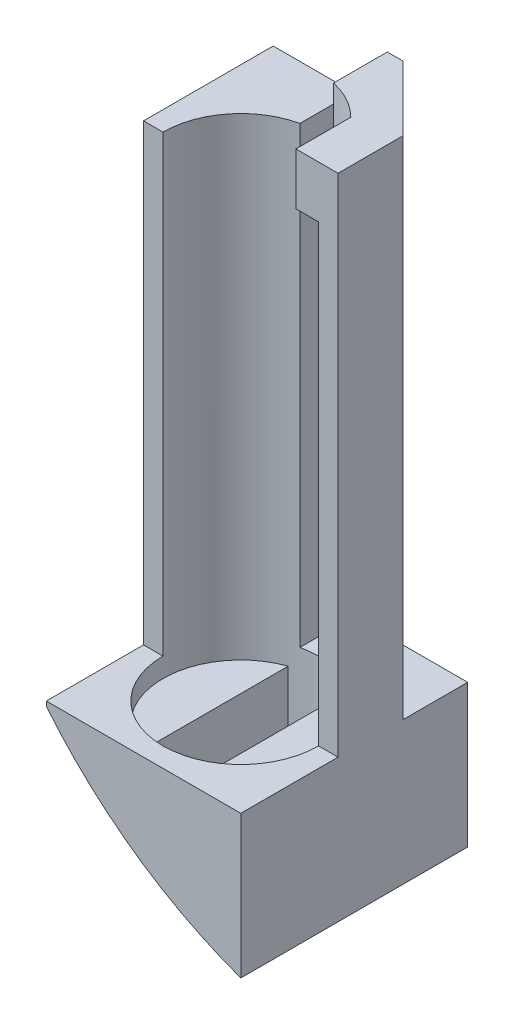
from build123d import *

# Parameters (mm, degrees)
BOSS_EXTRUDE1_DEPTH     = 70
SKETCH5_W               = 30
SKETCH5_H               = 35
BOSS_EXTRUDE3_DEPTH     = 22
SKETCH6_R               = 108.03554
SKETCH6_R_2             = 69
CUT_EXTRUDE1_DEPTH      = 16
CUT_EXTRUDE1_DEPTH_BACK = 21
SKETCH7_R               = 12
CUT_EXTRUDE2_DEPTH      = 3
CUT_EXTRUDE3_DEPTH      = 23
BOSS_EXTRUDE4_DEPTH     = 8


with BuildPart() as part:
    # Sketch1 → Boss-Extrude1 (new body)
    with BuildSketch(Plane(origin=(0, 0, 0), x_dir=(-1, 0, 0), z_dir=(0, 1, 0))):
        with BuildLine():
            Line((-12, 0), (-15, 0))
            Line((-15, 0), (-15, -10))
            Line((-15, -10), (-5, -20))
            Line((-5, -20), (15, -20))
            Line((15, -20), (15, 0))
            Line((15, 0), (12, 0))
            ThreePointArc((12, 0), (9.359487, -7.509993), (2.6, -11.714948))
            Line((2.6, -11.714948), (2.6, -17.2))
            Line((2.6, -17.2), (-2.6, -17.2))
            Line((-2.6, -17.2), (-2.6, -11.714948))
            ThreePointArc((-2.6, -11.714948), (-9.359487, -7.509993), (-12, 0))
        make_face()
    extrude(amount=BOSS_EXTRUDE1_DEPTH)

    # Sketch5 → Boss-Extrude3 (add)
    with BuildSketch(Plane(origin=(0, 0, 0), x_dir=(-1, 0, 0), z_dir=(0, 1, 0))):
        with Locations((0, -2.5)):
            Rectangle(SKETCH5_W, SKETCH5_H)
    extrude(amount=-BOSS_EXTRUDE3_DEPTH)

    # Sketch6 → Cut-Extrude1 (cut, two sides)
    with BuildSketch(Plane(origin=(0, 0, 0), x_dir=(0, 1, 0), z_dir=(0, 0, 1))) as cut_extrude1_sk:
        with Locations((42.87488, -38.5)):
            Circle(SKETCH6_R)
        with Locations((42.87488, -38.5)):
            Circle(SKETCH6_R_2, mode=Mode.SUBTRACT)
    extrude(amount=CUT_EXTRUDE1_DEPTH, mode=Mode.SUBTRACT)
    extrude(cut_extrude1_sk.sketch, amount=-CUT_EXTRUDE1_DEPTH_BACK, mode=Mode.SUBTRACT)

    # Sketch7 → Cut-Extrude2 (cut)
    with BuildSketch(Plane(origin=(0, 0, 0), x_dir=(-1, 0, 0), z_dir=(0, 1, 0))):
        Circle(SKETCH7_R)
    extrude(amount=-CUT_EXTRUDE2_DEPTH, mode=Mode.SUBTRACT)

    # Sketch8 → Cut-Extrude3 (cut, through all)
    with BuildSketch(Plane(origin=(0, 0, 0), x_dir=(-1, 0, 0), z_dir=(0, 1, 0))):
        with BuildLine():
            Line((-4, 11.313708), (-4, -11.313708))
            ThreePointArc((-4, -11.313708), (0, -12), (4, -11.313708))
            Line((4, -11.313708), (4, 11.313708))
            ThreePointArc((4, 11.313708), (0, 12), (-4, 11.313708))
        make_face()
    extrude(amount=-CUT_EXTRUDE3_DEPTH, mode=Mode.SUBTRACT)

    # Sketch10 → Boss-Extrude4 (add)
    with BuildSketch(Plane(origin=(0, 70, 0), x_dir=(-1, 0, 0), z_dir=(0, 1, 0))):
        with BuildLine():
            Line((-15, -10), (-5, -20))
            Line((-5, -20), (-2.6, -20))
            Line((-2.6, -20), (-2.6, -11.714948))
            ThreePointArc((-2.6, -11.714948), (-5.782218, -10.515034), (-8.5, -8.470537))
            Line((-8.5, -8.470537), (-8.5, 0))
            Line((-8.5, 0), (-15, 0))
            Line((-15, 0), (-15, -10))
        make_face()
    extrude(amount=BOSS_EXTRUDE4_DEPTH)


solid = part.part
